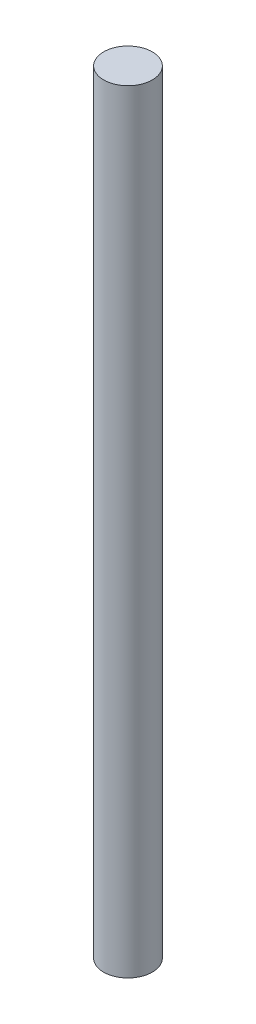
from build123d import *

# Parameters (mm, degrees)
SKETCH1_R           = 6.3
BOSS_EXTRUDE1_DEPTH = 200


with BuildPart() as part:
    # Sketch1 → Boss-Extrude1 (new body)
    with BuildSketch(Plane(origin=(0, 0, 0), x_dir=(1, 0, 0), z_dir=(0, 1, 0))):
        Circle(SKETCH1_R)
    extrude(amount=BOSS_EXTRUDE1_DEPTH)


solid = part.part
